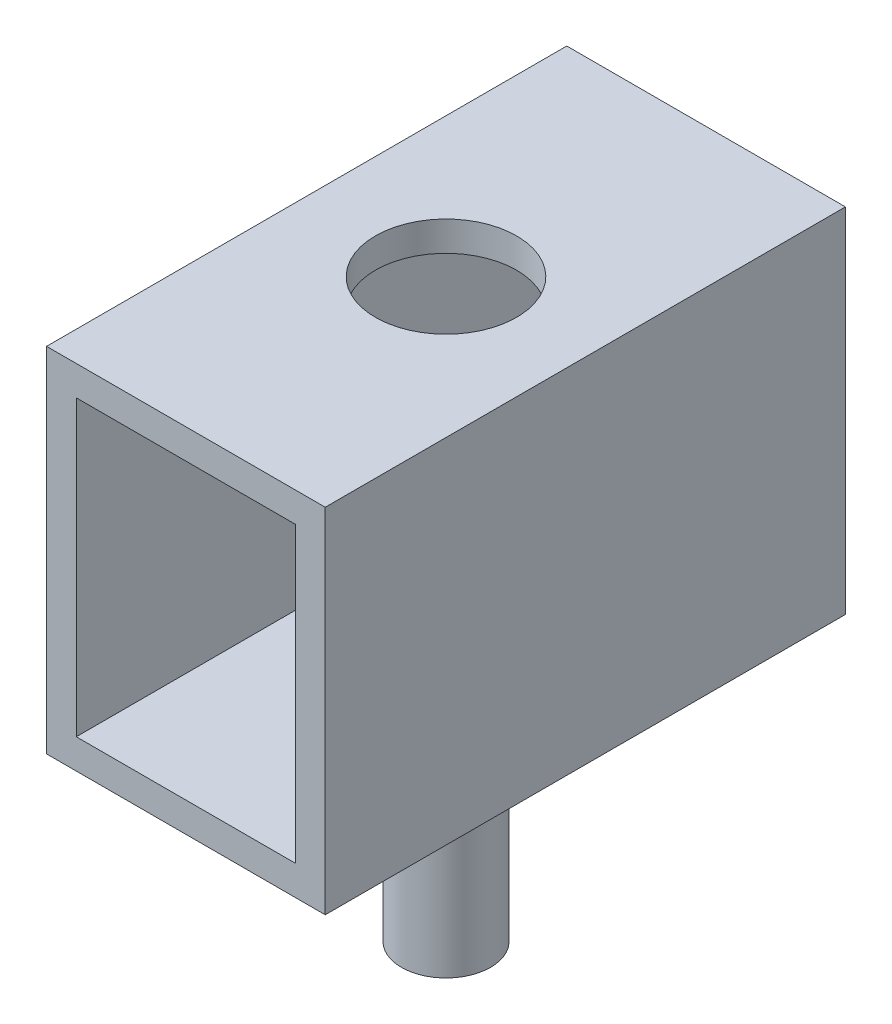
from build123d import *

# Parameters (mm, degrees)
SKETCH1_W           = 3.75
SKETCH1_H           = 4.75
SKETCH1_W_2         = 2.95
SKETCH1_H_2         = 3.95
BOSS_EXTRUDE1_DEPTH = 7
SKETCH2_R           = 0.6
BOSS_EXTRUDE2_DEPTH = 3
SKETCH3_R           = 0.95
CUT_EXTRUDE4_DEPTH  = 0.4


with BuildPart() as part:
    # Sketch1 → Boss-Extrude1 (new body)
    with BuildSketch(Plane.XY):
        with Locations((0, 0.5)):
            Rectangle(SKETCH1_W, SKETCH1_H)
        with Locations((0, 0.5)):
            Rectangle(SKETCH1_W_2, SKETCH1_H_2, mode=Mode.SUBTRACT)
    extrude(amount=BOSS_EXTRUDE1_DEPTH)

    # Sketch3 → Cut-Extrude4 (cut)
    with BuildSketch(Plane(origin=(0, 2.875, 0), x_dir=(1, 0, 0), z_dir=(0, 1, 0))):
        with Locations(Location((0, -3.5, 0), (0, 0, 180))):  # turned: the seam where the file's is
            Circle(SKETCH3_R)
    extrude(amount=-CUT_EXTRUDE4_DEPTH, mode=Mode.SUBTRACT)


with BuildPart() as body_2:
    # Sketch2 → Boss-Extrude2 (new body)
    with BuildSketch(Plane(origin=(0, -1.875, 0), x_dir=(-1, 0, 0), z_dir=(0, -1, 0))):
        with Locations(Location((0, -3.5, 0), (0, 0, 180))):  # turned: the seam where the file's is
            Circle(SKETCH2_R)
    extrude(amount=BOSS_EXTRUDE2_DEPTH)


solid = Compound([part.part, body_2.part])
